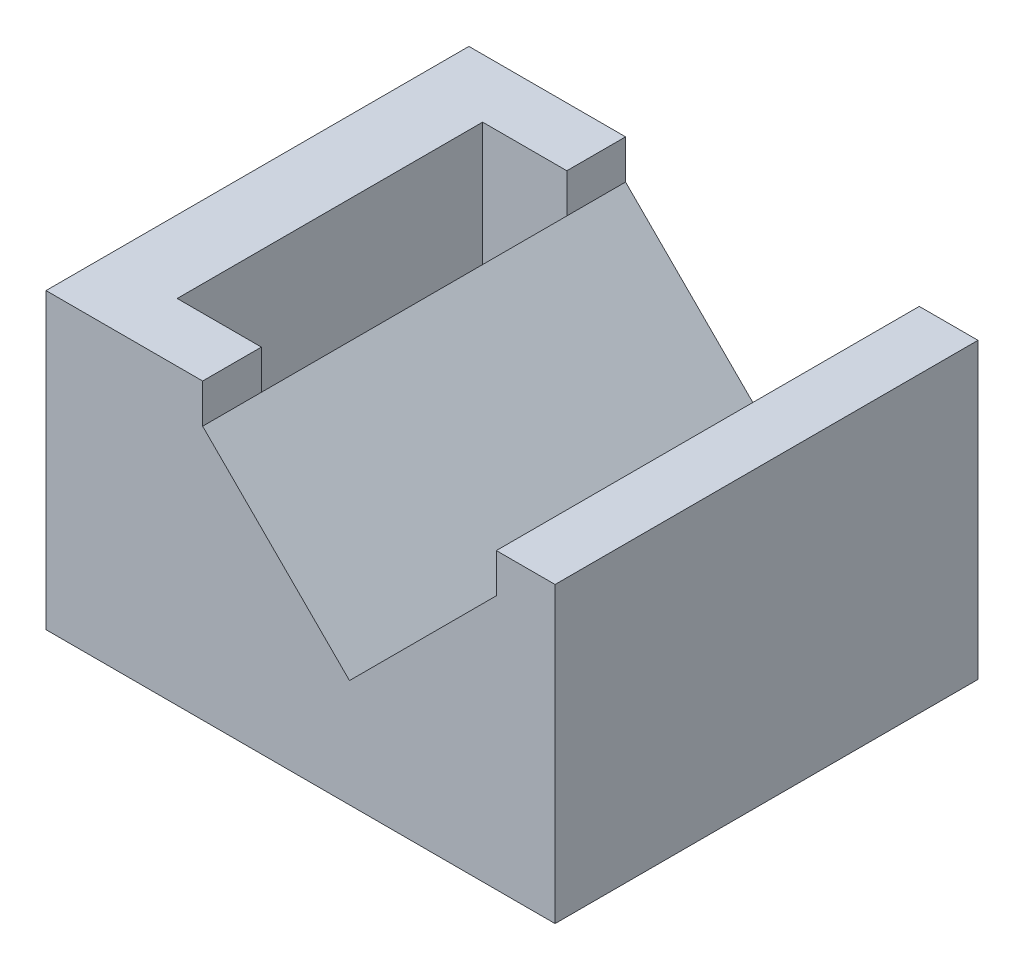
from build123d import *

# Parameters (mm, degrees)
RESSALTO_EXTRUS_O1_DEPTH   = 25
ESBO_O5_W                  = 4.3
ESBO_O5_H                  = 15.6
ESBO_O5_W_2                = 26
ESBO_O5_H_2                = 14.2
CORTE_EXTRUS_O4_DEPTH      = 1
CORTE_EXTRUS_O4_DEPTH_BACK = 16
RESSALTO_EXTRUS_O2_DEPTH   = 2.5


with BuildPart() as part:
    # Esboço1 → Ressalto-extrusão1 (new body, symmetric)
    with BuildSketch(Plane.XY):
        Polygon((26, 0), (0, 0), (0, 15), (8, 15), (8, 13), (15.5, 5.5), (23, 13), (23, 15), (26, 15), align=None)
    extrude(amount=RESSALTO_EXTRUS_O1_DEPTH, both=True)

    # Esboço5 → Corte-extrusão4 (cut, two sides)
    with BuildSketch(Plane(origin=(0, 15, 0), x_dir=(1, 0, 0), z_dir=(0, 1, 0))) as corte_extrus_o4_sk:
        with Locations((5.85, 0)):
            Rectangle(ESBO_O5_W, ESBO_O5_H)
        with Locations((13, 17.9)):
            Rectangle(ESBO_O5_W_2, ESBO_O5_H_2)
        with Locations((13, -17.9)):
            Rectangle(ESBO_O5_W_2, ESBO_O5_H_2)
    extrude(amount=CORTE_EXTRUS_O4_DEPTH, mode=Mode.SUBTRACT)
    extrude(corte_extrus_o4_sk.sketch, amount=-CORTE_EXTRUS_O4_DEPTH_BACK, mode=Mode.SUBTRACT)

    # Esboço6 → Ressalto-extrusão2 (add, symmetric)
    with BuildSketch(Plane.XY):
        Polygon((0, 8.5), (-3, 4), (-3, 1), (-2, 1), (0, 4), align=None)
    extrude(amount=RESSALTO_EXTRUS_O2_DEPTH, both=True)


solid = part.part
